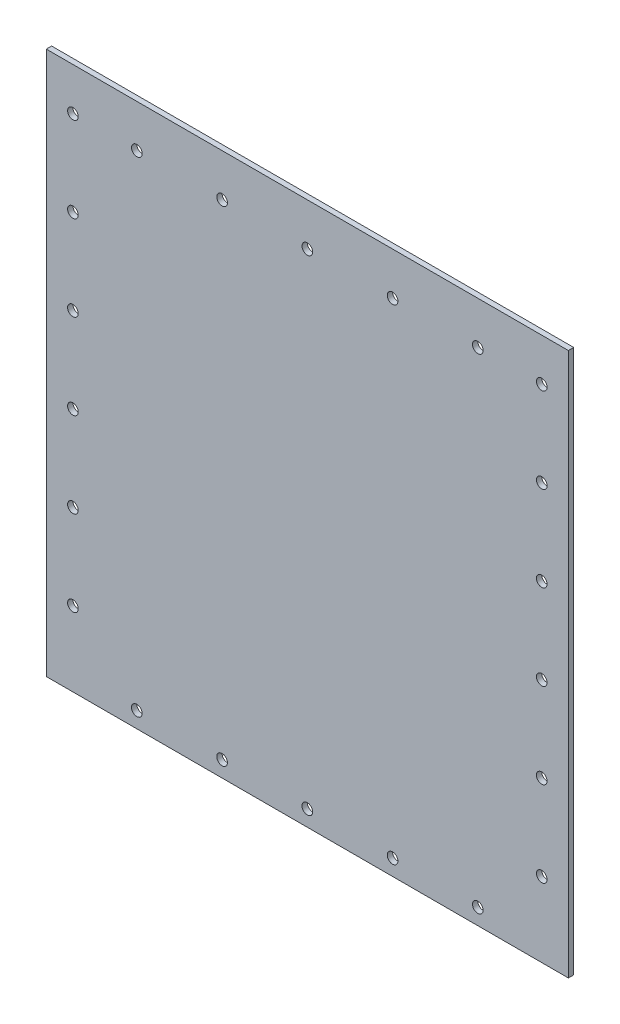
from build123d import *

# Parameters (mm, degrees)
SKETCH1_W           = 155.58
SKETCH1_H           = 161.922
SKETCH1_R           = 1.5875
BOSS_EXTRUDE1_DEPTH = 1.5875


with BuildPart() as part:
    # Sketch1 → Boss-Extrude1 (new body)
    with BuildSketch(Plane.XY):
        with Locations((77.79, -188.911)):
            Rectangle(SKETCH1_W, SKETCH1_H)
        with Locations((7.94, -247.65)):
            Circle(SKETCH1_R, mode=Mode.SUBTRACT)
        with Locations((26.987, -265.1125)):
            Circle(SKETCH1_R, mode=Mode.SUBTRACT)
        with Locations((7.94, -222.25)):
            Circle(SKETCH1_R, mode=Mode.SUBTRACT)
        with Locations((52.387, -265.1125)):
            Circle(SKETCH1_R, mode=Mode.SUBTRACT)
        with Locations((77.787, -265.1125)):
            Circle(SKETCH1_R, mode=Mode.SUBTRACT)
        with Locations((7.94, -196.85)):
            Circle(SKETCH1_R, mode=Mode.SUBTRACT)
        with Locations((7.94, -171.45)):
            Circle(SKETCH1_R, mode=Mode.SUBTRACT)
        with Locations((7.94, -146.05)):
            Circle(SKETCH1_R, mode=Mode.SUBTRACT)
        with Locations((103.187, -265.1125)):
            Circle(SKETCH1_R, mode=Mode.SUBTRACT)
        with Locations((128.587, -265.1125)):
            Circle(SKETCH1_R, mode=Mode.SUBTRACT)
        with Locations((147.64, -247.65)):
            Circle(SKETCH1_R, mode=Mode.SUBTRACT)
        with Locations((147.64, -222.25)):
            Circle(SKETCH1_R, mode=Mode.SUBTRACT)
        with Locations((147.64, -196.85)):
            Circle(SKETCH1_R, mode=Mode.SUBTRACT)
        with Locations((147.64, -171.45)):
            Circle(SKETCH1_R, mode=Mode.SUBTRACT)
        with Locations((147.64, -146.05)):
            Circle(SKETCH1_R, mode=Mode.SUBTRACT)
        with Locations((7.94, -120.65)):
            Circle(SKETCH1_R, mode=Mode.SUBTRACT)
        with Locations((26.99, -120.65)):
            Circle(SKETCH1_R, mode=Mode.SUBTRACT)
        with Locations((52.39, -120.65)):
            Circle(SKETCH1_R, mode=Mode.SUBTRACT)
        with Locations((77.79, -120.65)):
            Circle(SKETCH1_R, mode=Mode.SUBTRACT)
        with Locations((103.19, -120.65)):
            Circle(SKETCH1_R, mode=Mode.SUBTRACT)
        with Locations((128.59, -120.65)):
            Circle(SKETCH1_R, mode=Mode.SUBTRACT)
        with Locations((147.64, -120.65)):
            Circle(SKETCH1_R, mode=Mode.SUBTRACT)
    extrude(amount=BOSS_EXTRUDE1_DEPTH)


solid = part.part
